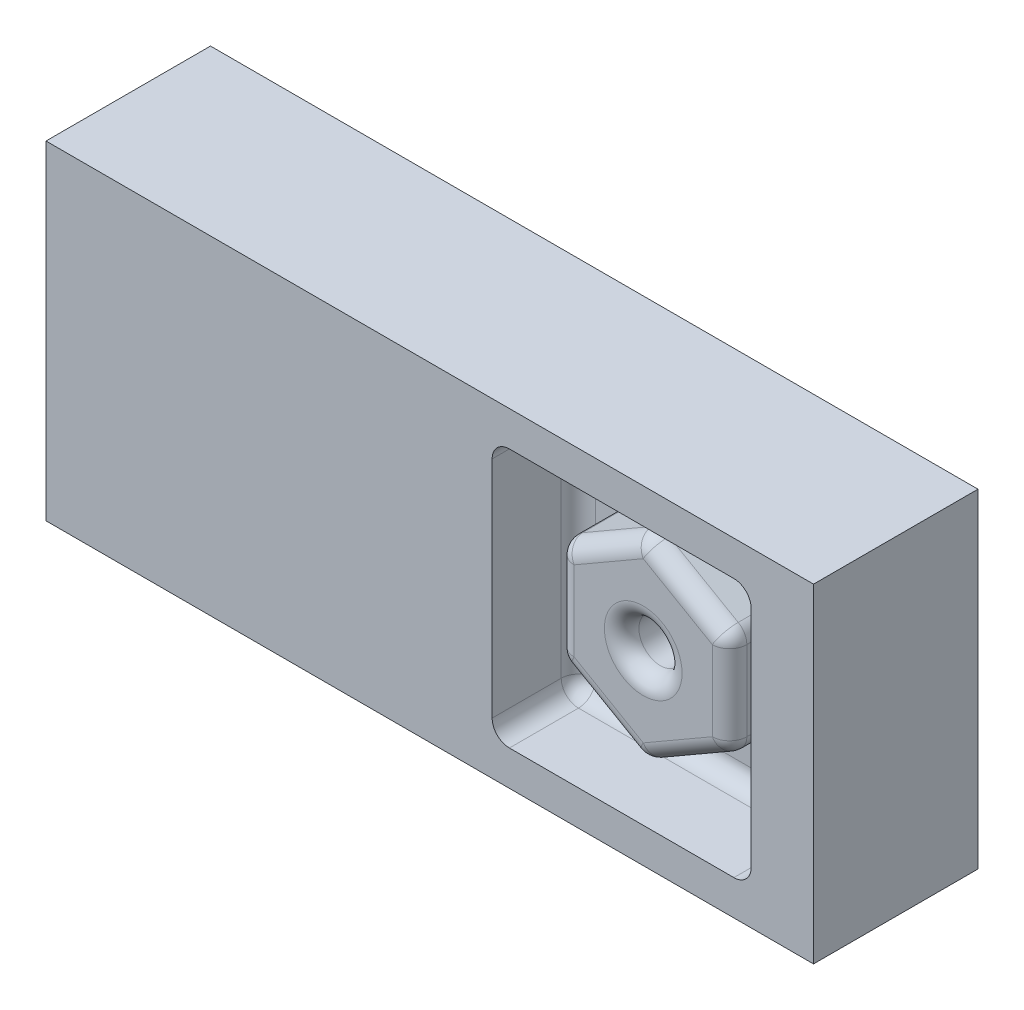
from build123d import *

# Parameters (mm, degrees)
CROQUIS1_W              = 177.8
CROQUIS1_H              = 76.2
SALIENTE_EXTRUIR1_DEPTH = 38.1
CROQUIS2_W              = 60
CROQUIS2_H              = 60
CORTAR_EXTRUIR1_DEPTH   = 20
CROQUIS3_R              = 5
SALIENTE_EXTRUIR2_DEPTH = 15
REDONDEO1_R             = 4
REDONDEO3_R             = 4
REDONDEO4_R             = 4
REDONDEO5_R             = 4


with BuildPart() as part:
    # Croquis1 → Saliente-Extruir1 (new body)
    with BuildSketch(Plane.XY):
        Rectangle(CROQUIS1_W, CROQUIS1_H)
    extrude(amount=SALIENTE_EXTRUIR1_DEPTH)

    # Croquis2 → Cortar-Extruir1 (cut)
    with BuildSketch(Plane.XY.offset(38.1)):
        with Locations((44.45, 0)):
            Rectangle(CROQUIS2_W, CROQUIS2_H)
    extrude(amount=-CORTAR_EXTRUIR1_DEPTH, mode=Mode.SUBTRACT)

    # Croquis3 → Saliente-Extruir2 (add)
    with BuildSketch(Plane.XY.offset(18.1)):
        Polygon((44.45, 23.094010768), (24.45, 11.547005384), (24.45, -11.547005384), (44.45, -23.094010768), (64.45, -11.547005384), (64.45, 11.547005384), align=None)
        with Locations((44.45, 0)):
            Circle(CROQUIS3_R, mode=Mode.SUBTRACT)
    extrude(amount=SALIENTE_EXTRUIR2_DEPTH)

    # Redondeo1
    redondeo1_edges = [part.edges().sort_by_distance(p)[0] for p in [
        (14.45, 0, 18.1),
        (14.45, -30, 28.1),
        (44.45, 30, 18.1),
        (14.45, 30, 28.1),
        (74.45, 0, 18.1),
        (74.45, 30, 28.1),
        (44.45, -30, 18.1),
        (74.45, -30, 28.1),
    ]]
    fillet(redondeo1_edges, radius=REDONDEO1_R)

    # Redondeo3
    redondeo3_edges = [part.edges().sort_by_distance(p)[0] for p in [
        (64.45, 11.547005384, 25.6),
        (44.45, 23.094010768, 25.6),
        (24.45, 11.547005384, 25.6),
        (24.45, -11.547005384, 25.6),
        (44.45, -23.094010768, 25.6),
        (64.45, -11.547005384, 25.6),
    ]]
    fillet(redondeo3_edges, radius=REDONDEO3_R)

    # Redondeo4
    redondeo4_edges = [part.edges().sort_by_distance(p)[0] for p in [
        (39.45, 0, 33.1),
    ]]
    fillet(redondeo4_edges, radius=REDONDEO4_R)

    # Redondeo5
    redondeo5_edges = [part.edges().sort_by_distance(p)[0] for p in [
        (44.45, 22.475208614, 33.1),
        (24.985898385, 11.237604307, 33.1),
        (24.985898385, -11.237604307, 33.1),
        (44.45, -22.475208614, 33.1),
        (63.914101615, -11.237604307, 33.1),
        (63.914101615, 11.237604307, 33.1),
        (54.45, 17.320508076, 33.1),
        (64.45, 0, 33.1),
        (34.45, 17.320508076, 33.1),
        (24.45, 0, 33.1),
        (34.45, -17.320508076, 33.1),
        (54.45, -17.320508076, 33.1),
    ]]
    fillet(redondeo5_edges, radius=REDONDEO5_R)


solid = part.part
